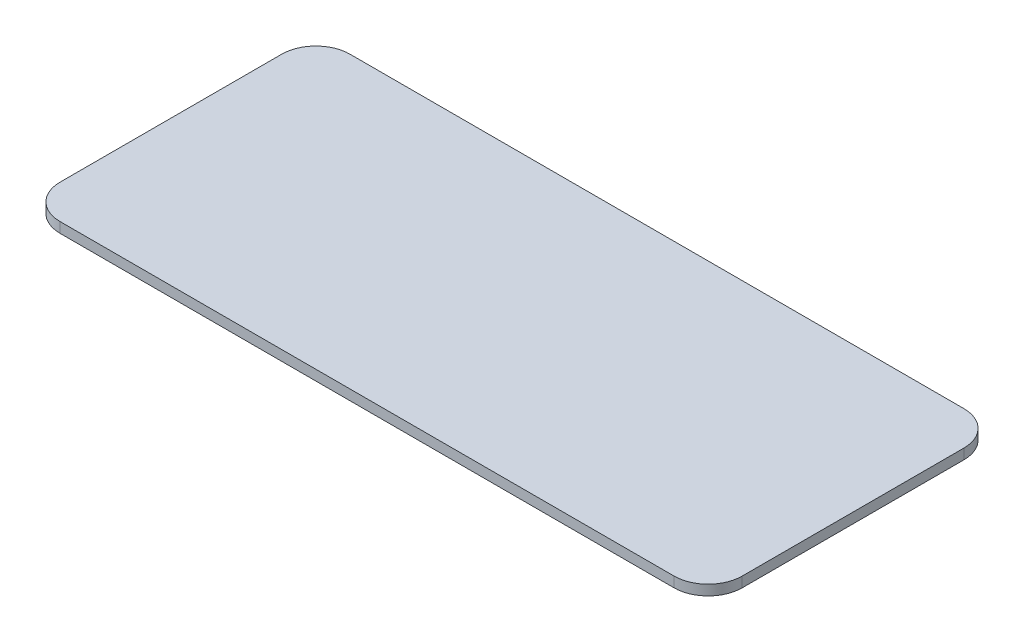
from build123d import *

# Parameters (mm, degrees)
BOSS_EXTRUDE2_DEPTH = 3


with BuildPart() as part:
    # Sketch1 → Boss-Extrude2 (new body)
    with BuildSketch(Plane(origin=(0, 0, 0), x_dir=(1, 0, 0), z_dir=(0, 1, 0))):
        with BuildLine():
            Line((-90, 42.5), (90, 42.5))
            ThreePointArc((90, 42.5), (97.071067812, 39.571067812), (100, 32.5))
            Line((100, 32.5), (100, -32.5))
            ThreePointArc((100, -32.5), (97.071067812, -39.571067812), (90, -42.5))
            Line((90, -42.5), (-90, -42.5))
            ThreePointArc((-90, -42.5), (-97.071067812, -39.571067812), (-100, -32.5))
            Line((-100, -32.5), (-100, 32.5))
            ThreePointArc((-100, 32.5), (-97.071067812, 39.571067812), (-90, 42.5))
        make_face()
    extrude(amount=BOSS_EXTRUDE2_DEPTH)


solid = part.part
